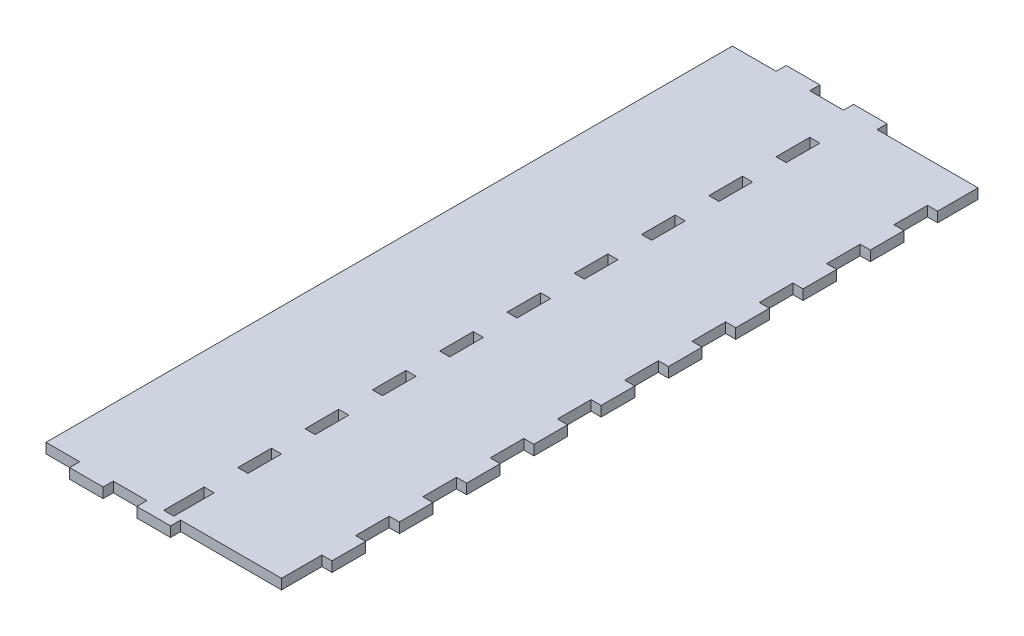
from build123d import *

# Parameters (mm, degrees)
SKETCH1_W                  = 70
SKETCH1_H                  = 204
BOSS_EXTRUDE1_DEPTH        = 3
SKETCH2_W                  = 12
SKETCH2_H                  = 3
SKETCH2_W_2                = 10
BOSS_EXTRUDE2_DEPTH        = 3
ESQUISSE4_W                = 3
ESQUISSE4_H                = 10
ENL_V_MAT_EXTRU_3_DEPTH    = 4
R_P_TITION_LIN_AIRE2_COUNT = 10
R_P_TITION_LIN_AIRE2_PITCH = 20
ESQUISSE5_W                = 3
ESQUISSE5_H                = 3
ENL_V_MAT_EXTRU_4_DEPTH    = 3
ESQUISSE6_W                = 10
ESQUISSE6_H                = 3
BOSS_EXTRU_1_DEPTH         = 3
ESQUISSE7_W                = 10
ESQUISSE7_H                = 3
BOSS_EXTRU_2_DEPTH         = 3


with BuildPart() as part:
    # Sketch1 → Boss-Extrude1 (new body)
    with BuildSketch(Plane(origin=(0, 0, 0), x_dir=(1, 0, 0), z_dir=(0, 1, 0))):
        with Locations((35, 102)):
            Rectangle(SKETCH1_W, SKETCH1_H)
    extrude(amount=BOSS_EXTRUDE1_DEPTH)

    # Sketch2 → Boss-Extrude2 (add)
    with BuildSketch(Plane(origin=(70, 0, 0), x_dir=(0, 0, -1), z_dir=(1, 0, 0))):
        with Locations((198, 1.5)):
            Rectangle(SKETCH2_W, SKETCH2_H)
        with Locations((177, 1.5)):
            Rectangle(SKETCH2_W_2, SKETCH2_H)
        with Locations((157, 1.5)):
            Rectangle(SKETCH2_W_2, SKETCH2_H)
        with Locations((137, 1.5)):
            Rectangle(SKETCH2_W_2, SKETCH2_H)
        with Locations((117, 1.5)):
            Rectangle(SKETCH2_W_2, SKETCH2_H)
        with Locations((97, 1.5)):
            Rectangle(SKETCH2_W_2, SKETCH2_H)
        with Locations((77, 1.5)):
            Rectangle(SKETCH2_W_2, SKETCH2_H)
        with Locations((57, 1.5)):
            Rectangle(SKETCH2_W_2, SKETCH2_H)
        with Locations((37, 1.5)):
            Rectangle(SKETCH2_W_2, SKETCH2_H)
        with Locations((17, 1.5)):
            Rectangle(SKETCH2_W_2, SKETCH2_H)
    extrude(amount=BOSS_EXTRUDE2_DEPTH)

    # Esquisse4 → Enlèv. mat.-Extru.3 (cut, through all)
    with BuildSketch(Plane(origin=(0, 3, 0), x_dir=(1, 0, 0), z_dir=(0, 1, 0))):
        with Locations((36.5, 187)):
            Rectangle(ESQUISSE4_W, ESQUISSE4_H)
    enl_v_mat_extru_3 = extrude(amount=-ENL_V_MAT_EXTRU_3_DEPTH, mode=Mode.SUBTRACT)

    # Répétition linéaire2: Enlèv. mat.-Extru.3 ×10
    with Locations(*[(0, 0, i * R_P_TITION_LIN_AIRE2_PITCH) for i in range(1, R_P_TITION_LIN_AIRE2_COUNT)]):
        add(enl_v_mat_extru_3, mode=Mode.SUBTRACT)

    # Esquisse5 → Enlèv. mat.-Extru.4 (cut, through all)
    with BuildSketch(Plane(origin=(0, 0, -2), x_dir=(-1, 0, 0), z_dir=(0, 0, -1))):
        with Locations((-36.5, 1.5)):
            Rectangle(ESQUISSE5_W, ESQUISSE5_H)
    extrude(amount=-ENL_V_MAT_EXTRU_4_DEPTH, mode=Mode.SUBTRACT)

    # Esquisse6 → Boss.-Extru.1 (add)
    with BuildSketch(Plane.XY):
        with Locations((15, 1.5)):
            Rectangle(ESQUISSE6_W, ESQUISSE6_H)
        with Locations((35, 1.5)):
            Rectangle(ESQUISSE6_W, ESQUISSE6_H)
    extrude(amount=BOSS_EXTRU_1_DEPTH)

    # Esquisse7 → Boss.-Extru.2 (add)
    with BuildSketch(Plane(origin=(0, 0, -204), x_dir=(-1, 0, 0), z_dir=(0, 0, -1))):
        with Locations((-38, 1.5)):
            Rectangle(ESQUISSE7_W, ESQUISSE7_H)
        with Locations((-18, 1.5)):
            Rectangle(ESQUISSE7_W, ESQUISSE7_H)
    extrude(amount=BOSS_EXTRU_2_DEPTH)


solid = part.part
